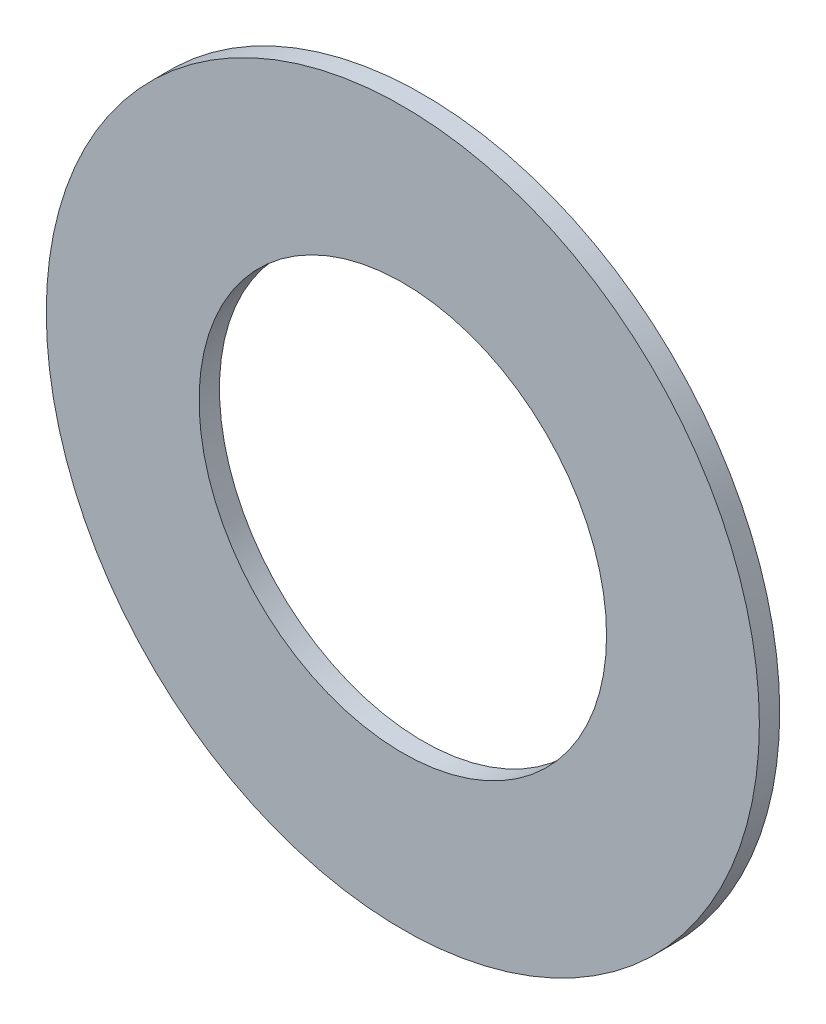
from build123d import *

# Parameters (mm, degrees)
SKETCH1_R           = 17.5
SKETCH1_R_2         = 10
BOSS_EXTRUDE1_DEPTH = 1


with BuildPart() as part:
    # Sketch1 → Boss-Extrude1 (new body)
    with BuildSketch(Plane.XY):
        Circle(SKETCH1_R)
        Circle(SKETCH1_R_2, mode=Mode.SUBTRACT)
    extrude(amount=BOSS_EXTRUDE1_DEPTH)


solid = part.part
